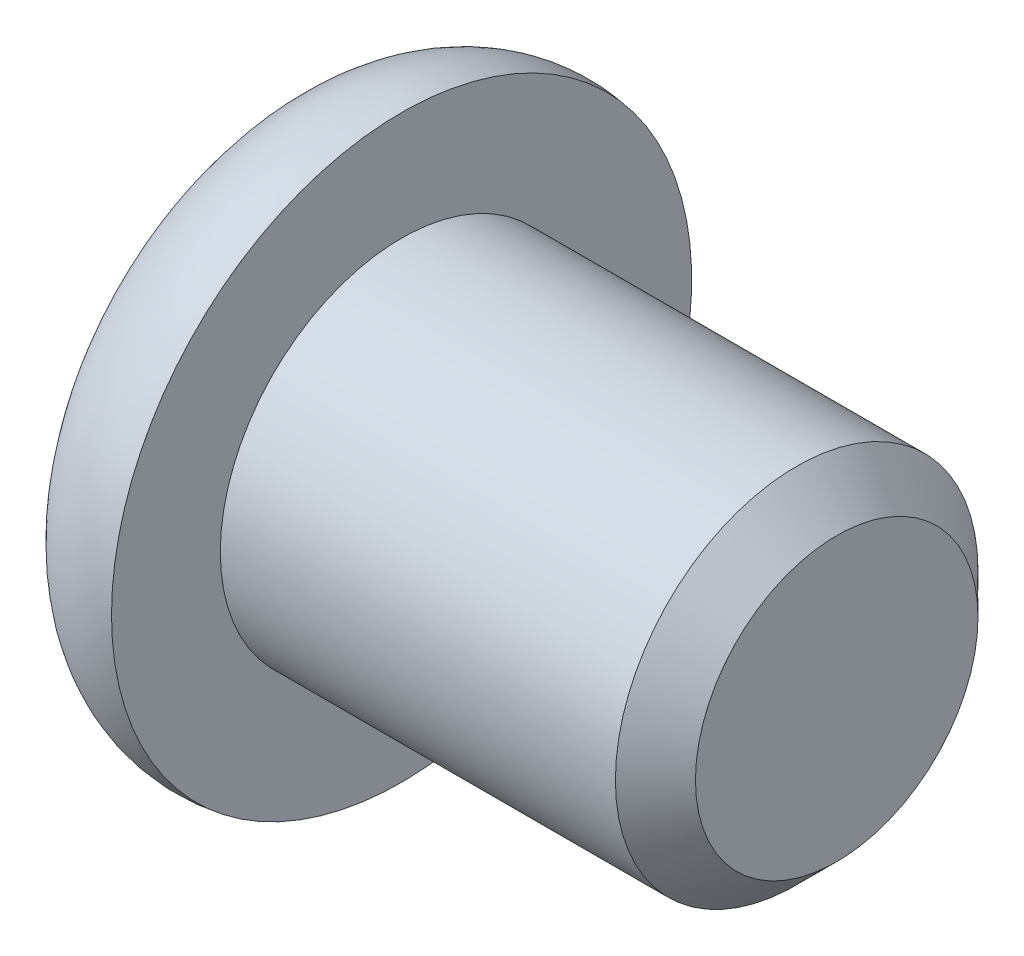
from build123d import *

# Parameters (mm, degrees)
CUT_EXTRUDE1_DEPTH      = 0.2
CUT_EXTRUDE1_DEPTH_BACK = 0.2
CUT_EXTRUDE2_DEPTH      = 0.2
CUT_EXTRUDE2_DEPTH_BACK = 0.2


with BuildPart() as part:
    # Sketch1 → Revolve1 (revolve)
    with BuildSketch(Plane.XY):
        with BuildLine():
            Line((-0.8, 0), (-0.8, 1.6))
            ThreePointArc((-0.8, 1.6), (-0.466151956, 1.932303913), (0, 2))
            Line((0, 2), (0, 1.25))
            Line((0, 1.25), (2.724, 1.25))
            Line((2.724, 1.25), (3, 0.974))
            Line((3, 0.974), (3, 0))
            Line((3, 0), (-0.8, 0))
        make_face()
    revolve(axis=Axis((3, 0, 0), (-1, 0, 0)))

    # Sketch2 → Cut-Extrude1 (cut, two sides: drawn at the far end of the back side and taken through both)
    with BuildSketch(Plane.XY.offset(-CUT_EXTRUDE1_DEPTH_BACK)):
        Polygon((-0.8, -1.2), (0.4, -0.6), (0.6, 0), (0.4, 0.6), (-0.8, 1.2), align=None)
    extrude(amount=CUT_EXTRUDE1_DEPTH + CUT_EXTRUDE1_DEPTH_BACK, mode=Mode.SUBTRACT)

    # Sketch3 → Cut-Extrude2 (cut, two sides: drawn at the far end of the back side and taken through both)
    with BuildSketch(Plane(origin=(0, 0, 0), x_dir=(1, 0, 0), z_dir=(0, 1, 0)).offset(-CUT_EXTRUDE2_DEPTH_BACK)):
        Polygon((-0.8, -1.2), (0.4, -0.6), (0.6, 0), (0.4, 0.6), (-0.8, 1.2), align=None)
    extrude(amount=CUT_EXTRUDE2_DEPTH + CUT_EXTRUDE2_DEPTH_BACK, mode=Mode.SUBTRACT)


solid = part.part
